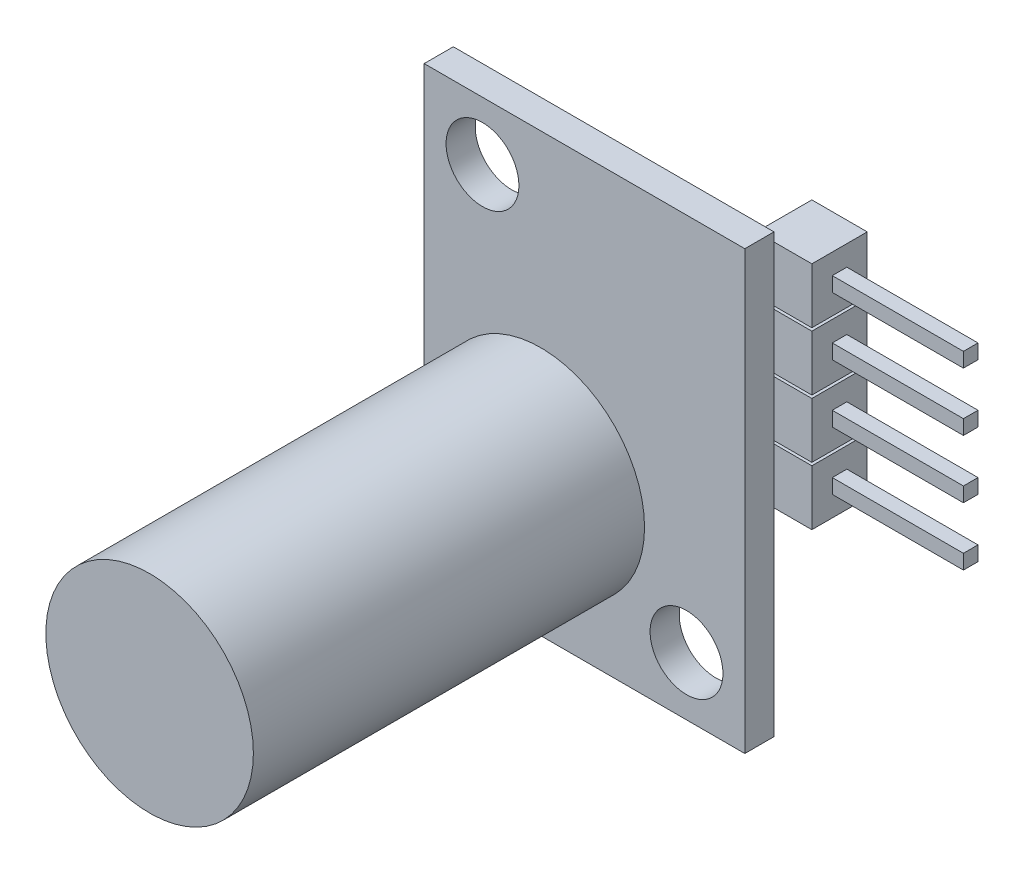
from build123d import *

# Parameters (mm, degrees)
SKETCH1_W           = 13.97
SKETCH1_H           = 19.05
SKETCH1_R           = 1.5875
BOSS_EXTRUDE1_DEPTH = 1.27
SKETCH2_R           = 4.5212
BOSS_EXTRUDE2_DEPTH = 17.0434
SKETCH3_W           = 2.413
SKETCH3_H           = 2.413
BOSS_EXTRUDE3_DEPTH = 2.413
SKETCH4_W           = 0.635
SKETCH4_H           = 0.635
BOSS_EXTRUDE4_DEPTH = 5.715


with BuildPart() as part:
    # Sketch1 → Boss-Extrude1 (new body)
    with BuildSketch(Plane.XY):
        with Locations((6.985, 9.525)):
            Rectangle(SKETCH1_W, SKETCH1_H)
        with Locations((2.54, 16.51)):
            Circle(SKETCH1_R, mode=Mode.SUBTRACT)
        with Locations((11.43, 2.54)):
            Circle(SKETCH1_R, mode=Mode.SUBTRACT)
    extrude(amount=BOSS_EXTRUDE1_DEPTH)

    # Sketch2 → Boss-Extrude2 (add)
    with BuildSketch(Plane.XY.offset(1.27)):
        with Locations((5.08, 6.35)):
            Circle(SKETCH2_R)
    extrude(amount=BOSS_EXTRUDE2_DEPTH)

    # Sketch3 → Boss-Extrude3 (add)
    with BuildSketch(Plane(origin=(0, 0, 0), x_dir=(-1, 0, 0), z_dir=(0, 0, -1))):
        with Locations((-14.4145, 9.8425)):
            Rectangle(SKETCH3_W, SKETCH3_H)
        with Locations((-14.4145, 12.3825)):
            Rectangle(SKETCH3_W, SKETCH3_H)
        with Locations((-14.4145, 14.9225)):
            Rectangle(SKETCH3_W, SKETCH3_H)
        with Locations((-14.4145, 17.4625)):
            Rectangle(SKETCH3_W, SKETCH3_H)
    extrude(amount=BOSS_EXTRUDE3_DEPTH)

    # Sketch4 → Boss-Extrude4 (add)
    with BuildSketch(Plane(origin=(15.621, 0, 0), x_dir=(0, 0, -1), z_dir=(1, 0, 0))):
        with Locations((1.2065, 9.8425)):
            Rectangle(SKETCH4_W, SKETCH4_H)
        with Locations((1.2065, 12.3825)):
            Rectangle(SKETCH4_W, SKETCH4_H)
        with Locations((1.2065, 14.9225)):
            Rectangle(SKETCH4_W, SKETCH4_H)
        with Locations((1.2065, 17.4625)):
            Rectangle(SKETCH4_W, SKETCH4_H)
    extrude(amount=BOSS_EXTRUDE4_DEPTH)


solid = part.part
